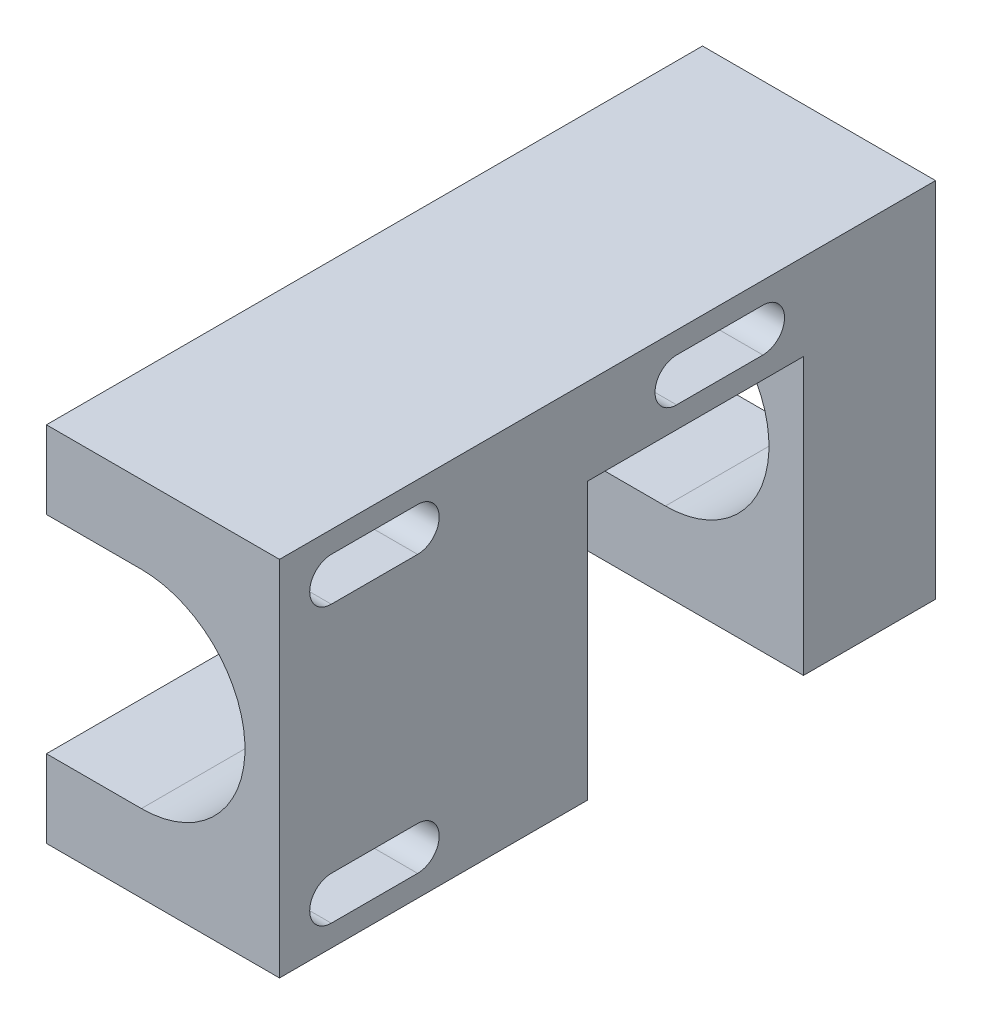
from build123d import *

# Parameters (mm, degrees)
SKETCH2_W           = 27
SKETCH2_H           = 42
BOSS_EXTRUDE1_DEPTH = 76
CUT_EXTRUDE1_DEPTH  = 28
CUT_EXTRUDE2_DEPTH  = 77
SKETCH5_W           = 25
SKETCH5_H           = 32
CUT_EXTRUDE3_DEPTH  = 28


with BuildPart() as part:
    # Sketch2 → Boss-Extrude1 (new body)
    with BuildSketch(Plane.XY):
        with Locations((13.5, 21)):
            Rectangle(SKETCH2_W, SKETCH2_H)
    extrude(amount=-BOSS_EXTRUDE1_DEPTH)

    # Sketch3 → Cut-Extrude1 (cut, through all)
    with BuildSketch(Plane.ZY):
        with BuildLine():
            Line((-56, 39.5), (-46, 39.5))
            ThreePointArc((-46, 39.5), (-43.5, 37), (-46, 34.5))
            Line((-46, 34.5), (-56, 34.5))
            ThreePointArc((-56, 34.5), (-58.5, 37), (-56, 39.5))
        make_face()
        with BuildLine():
            Line((-16, 39.5), (-6, 39.5))
            ThreePointArc((-6, 39.5), (-3.5, 37), (-6, 34.5))
            Line((-6, 34.5), (-16, 34.5))
            ThreePointArc((-16, 34.5), (-18.5, 37), (-16, 39.5))
        make_face()
        with BuildLine():
            Line((-16, 7.5), (-6, 7.5))
            ThreePointArc((-6, 7.5), (-3.5, 5), (-6, 2.5))
            Line((-6, 2.5), (-16, 2.5))
            ThreePointArc((-16, 2.5), (-18.5, 5), (-16, 7.5))
        make_face()
    extrude(amount=-CUT_EXTRUDE1_DEPTH, mode=Mode.SUBTRACT)

    # Sketch4 → Cut-Extrude2 (cut, through all)
    with BuildSketch(Plane.XY):
        with BuildLine():
            Line((11, 33), (0, 33))
            Line((0, 33), (0, 9))
            Line((0, 9), (11, 9))
            ThreePointArc((11, 9), (23, 21), (11, 33))
        make_face()
    extrude(amount=-CUT_EXTRUDE2_DEPTH, mode=Mode.SUBTRACT)

    # Sketch5 → Cut-Extrude3 (cut, through all)
    with BuildSketch(Plane(origin=(27, 0, 0), x_dir=(0, 0, -1), z_dir=(1, 0, 0))):
        with Locations((48.2, 16)):
            Rectangle(SKETCH5_W, SKETCH5_H)
    extrude(amount=-CUT_EXTRUDE3_DEPTH, mode=Mode.SUBTRACT)


solid = part.part
